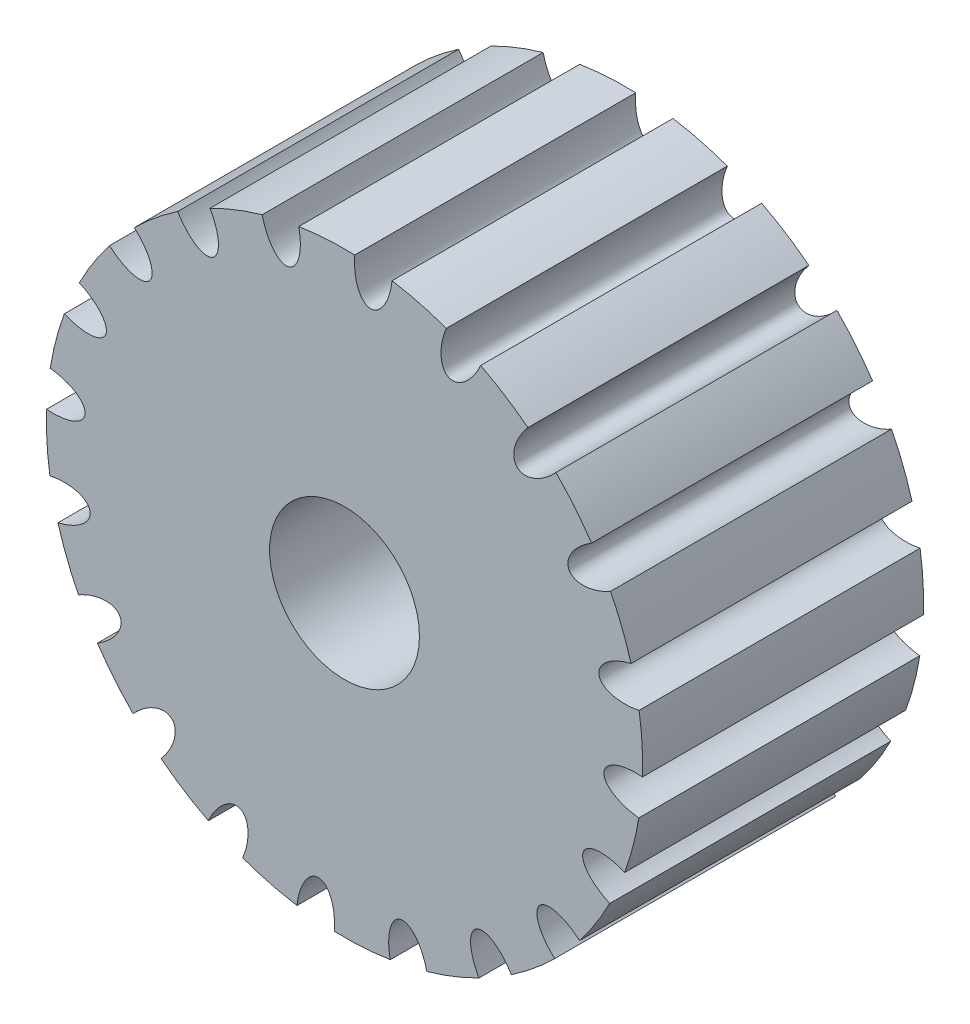
from build123d import *

# Parameters (mm, degrees)
SKETCH_1_R               = 15.91549431
EXTRUDE_2_DEPTH          = 15
SKETCH_2_R               = 4
CUT_EXTRUDE_1_DEPTH      = 15
SKETCH_3_RX              = 2
SKETCH_3_RY              = 1
CUT_EXTRUDE_2_DEPTH      = 15
PATTERN_CIRCULAR_1_COUNT = 20


with BuildPart() as part:
    # Эскиз1 → Бобышка-Вытянуть2 (new body)
    with BuildSketch(Plane.XY):
        Circle(SKETCH_1_R)
    extrude(amount=EXTRUDE_2_DEPTH)

    # Эскиз2 → Вырез-Вытянуть1 (cut)
    with BuildSketch(Plane.XY.offset(15)):
        Circle(SKETCH_2_R)
    extrude(amount=-CUT_EXTRUDE_1_DEPTH, mode=Mode.SUBTRACT)

    # Эскиз3 → Вырез-Вытянуть2 (cut)
    with BuildSketch(Plane.XY.offset(15)):
        with Locations(Location((13.72327338, 8.060690222), (0, 0, 30.428856936))):
            Ellipse(SKETCH_3_RX, SKETCH_3_RY)
    cut_extrude_2 = extrude(amount=-CUT_EXTRUDE_2_DEPTH, mode=Mode.SUBTRACT)

    # Круговой массив1: Вырез-Вытянуть2 ×20 about axis
    pattern_circular_1_axis = Axis((0, 0, 15), (0, 0, 1))
    for i in range(1, PATTERN_CIRCULAR_1_COUNT):
        add(cut_extrude_2.rotate(pattern_circular_1_axis, i * 360 / PATTERN_CIRCULAR_1_COUNT), mode=Mode.SUBTRACT)


solid = part.part
